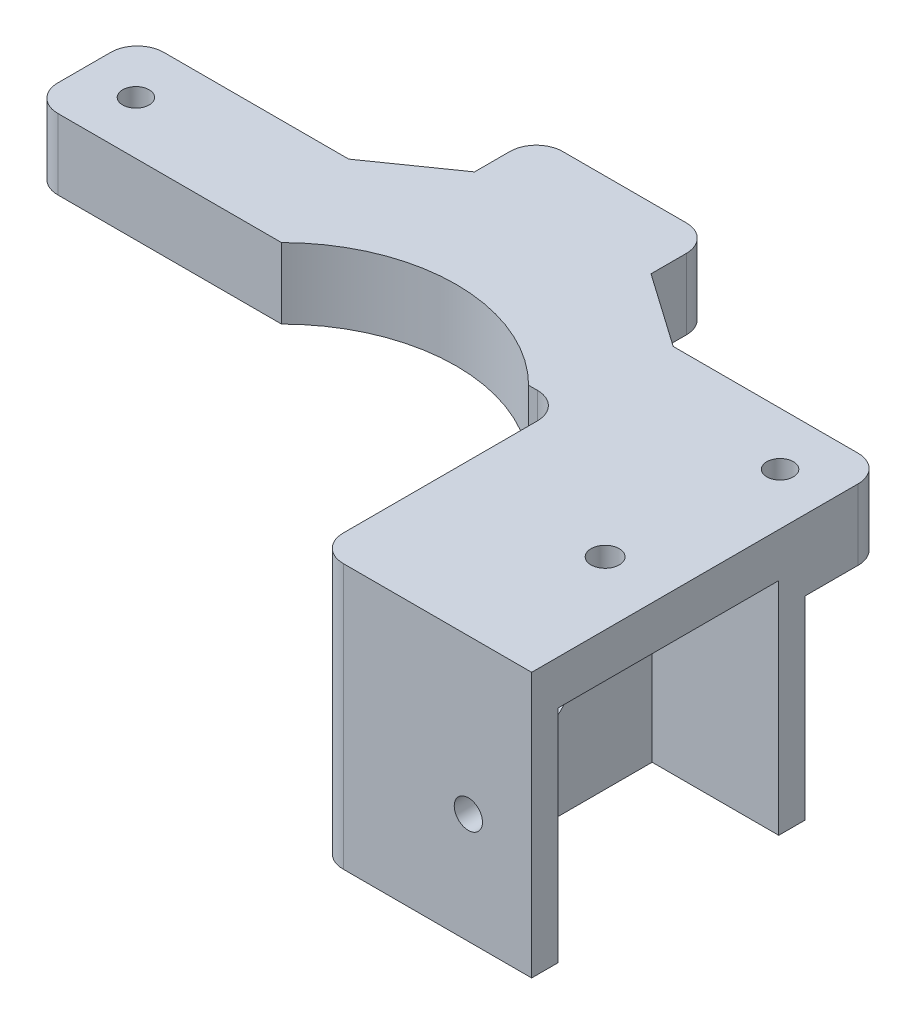
from build123d import *

# Parameters (mm, degrees)
SKETCH2_R           = 1.5
BOSS_EXTRUDE1_DEPTH = 8
SKETCH11_W          = 24.345630124
SKETCH11_H          = 31
BOSS_EXTRUDE4_DEPTH = 30
SKETCH12_W          = 25
SKETCH12_H          = 25
CUT_EXTRUDE7_DEPTH  = 14.34563
CUT_EXTRUDE8_REACH  = 26.346
SKETCH13_R          = 3.1
SKETCH14_R          = 5
CUT_EXTRUDE9_DEPTH  = 5.5
SKETCH15_R          = 1.6
CUT_EXTRUDE10_DEPTH = 5.5
CUT_EXTRUDE11_REACH = 32
SKETCH16_R          = 1.6
CUT_EXTRUDE12_DEPTH = 2.6
FILLET2_R           = 3


with BuildPart() as part:
    # Sketch2 → Boss-Extrude1 (new body)
    with BuildSketch(Plane(origin=(0, 0, 0), x_dir=(1, 0, 0), z_dir=(0, 1, 0))):
        with BuildLine():
            Line((-38.837197709, 64.4109018), (-14.876439197, 64.4109018))
            Line((-14.876439197, 64.4109018), (-6.491567585, 70.282052109))
            Line((-6.491567585, 70.282052109), (-6.491567585, 77.282052109))
            Line((-6.491567585, 77.282052109), (13.508432415, 77.282052109))
            Line((13.508432415, 77.282052109), (13.508432415, 70.282052109))
            Line((13.508432415, 70.282052109), (21.893304027, 64.4109018))
            Line((21.893304027, 64.4109018), (45.85406254, 64.4109018))
            Line((45.85406254, 64.4109018), (45.85406254, 52.4109018))
            Line((45.85406254, 52.4109018), (17.508432415, 52.4109018))
            ThreePointArc((17.508432415, 52.4109018), (3.508432415, 58.207416665), (-10.491567585, 52.4109018))
            Line((-10.491567585, 52.4109018), (-38.837197709, 52.4109018))
            Line((-38.837197709, 52.4109018), (-38.837197709, 64.4109018))
        make_face()
        with Locations((-32.991567585, 58.4109018)):
            Circle(SKETCH2_R, mode=Mode.SUBTRACT)
        with Locations((40.008432415, 58.4109018)):
            Circle(SKETCH2_R, mode=Mode.SUBTRACT)
    extrude(amount=BOSS_EXTRUDE1_DEPTH)

    # Sketch11 → Boss-Extrude4 (add)
    with BuildSketch(Plane(origin=(0, 8, 0), x_dir=(-1, 0, 0), z_dir=(0, -1, 0))):
        with Locations((26.664382647, 39.9109018)):
            Rectangle(SKETCH11_W, SKETCH11_H)
    extrude(amount=BOSS_EXTRUDE4_DEPTH)

    # Sketch12 → Cut-Extrude7 (cut)
    with BuildSketch(Plane.ZY.offset(38.837197709)):
        with Locations((-39.9109018, -9.5)):
            Rectangle(SKETCH12_W, SKETCH12_H)
    extrude(amount=-CUT_EXTRUDE7_DEPTH, mode=Mode.SUBTRACT)

    # Sketch13 → Cut-Extrude8 (cut, up to next)
    with BuildSketch(Plane(origin=(-14.491567585, 0, 0), x_dir=(0, 0, -1), z_dir=(1, 0, 0)), mode=Mode.PRIVATE) as cut_extrude8_sk1:
        with Locations((39.9109018, -9.5)):
            Circle(SKETCH13_R)
    cut_extrude8_tool1 = extrude(cut_extrude8_sk1.sketch, amount=-CUT_EXTRUDE8_REACH, mode=Mode.PRIVATE) & part.part
    add(cut_extrude8_tool1.solids().sort_by_distance((-14.491568, -9.5, -39.910902))[0], mode=Mode.SUBTRACT)

    # Sketch14 → Cut-Extrude9 (cut)
    with BuildSketch(Plane(origin=(-14.491567585, 0, 0), x_dir=(0, 0, -1), z_dir=(1, 0, 0))):
        with Locations((39.9109018, -9.5)):
            Circle(SKETCH14_R)
    extrude(amount=-CUT_EXTRUDE9_DEPTH, mode=Mode.SUBTRACT)

    # Sketch15 → Cut-Extrude10 (cut)
    with BuildSketch(Plane.XY.offset(-24.4109018)):
        with Locations((-31.664382647, -9.5)):
            Circle(SKETCH15_R)
    extrude(amount=-CUT_EXTRUDE10_DEPTH, mode=Mode.SUBTRACT)

    # Sketch16 → Cut-Extrude11 (cut, up to next)
    with BuildSketch(Plane(origin=(0, 8, 0), x_dir=(1, 0, 0), z_dir=(0, 1, 0)), mode=Mode.PRIVATE) as cut_extrude11_sk1:
        with Locations((-31.664382647, 39.9109018)):
            Circle(SKETCH16_R)
    cut_extrude11_tool1 = extrude(cut_extrude11_sk1.sketch, amount=-CUT_EXTRUDE11_REACH, mode=Mode.PRIVATE) & part.part
    add(cut_extrude11_tool1.solids().sort_by_distance((-31.664383, 8, -39.910902))[0], mode=Mode.SUBTRACT)

    # Sketch17 → Cut-Extrude12 (cut)
    with BuildSketch(Plane.XZ):
        Polygon((-31.259516777, -61.4109018), (-29.52746597, -58.4109018), (-31.259516777, -55.4109018), (-34.723618392, -55.4109018), (-36.4556692, -58.4109018), (-34.723618392, -61.4109018), align=None)
        Polygon((38.276381608, -61.4109018), (41.740483223, -61.4109018), (43.47253403, -58.4109018), (41.740483223, -55.4109018), (38.276381608, -55.4109018), (36.5443308, -58.4109018), align=None)
    extrude(amount=-CUT_EXTRUDE12_DEPTH, mode=Mode.SUBTRACT)

    # Fillet2
    fillet2_edges = [part.edges().sort_by_distance(p)[0] for p in [
        (-38.837197709, 4, -64.4109018),
        (-6.491567585, 4, -77.282052109),
        (13.508432415, 4, -77.282052109),
        (45.85406254, 4, -64.4109018),
        (45.85406254, 4, -52.4109018),
        (-14.491567585, 4, -52.4109018),
        (-14.491567585, -7, -24.4109018),
    ]]
    fillet(fillet2_edges, radius=FILLET2_R)


with BuildPart() as body_2:
    # Mirror2: mirrored copy
    add(part.part.mirror(Plane(origin=(45.85406254, 8, -64.4109018), x_dir=(0, 0, 1), z_dir=(-1, 0, 0))))


solid = body_2.part
